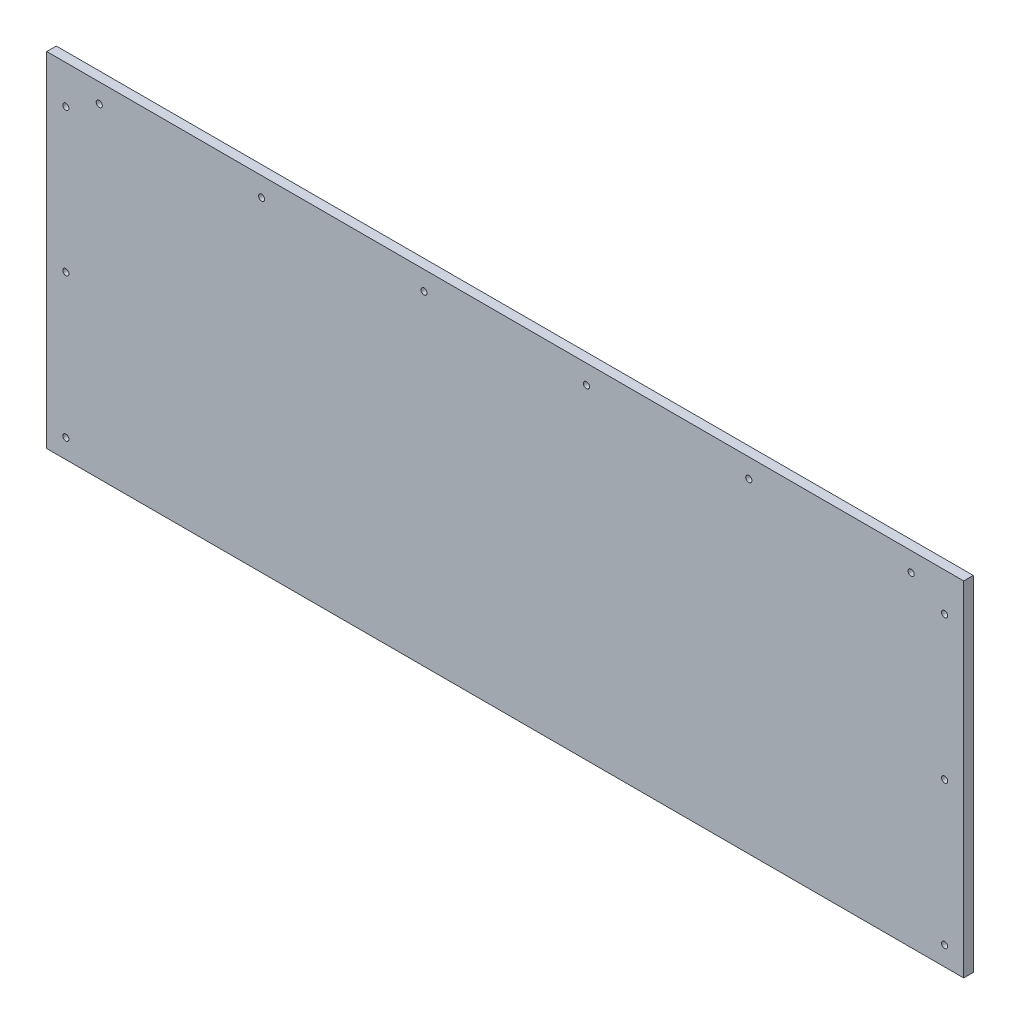
from build123d import *

# Parameters (mm, degrees)
SKETCH1_W           = 609.6
SKETCH1_H           = 228.6
BOSS_EXTRUDE1_DEPTH = 6.35
SKETCH2_R           = 2.032
CUT_EXTRUDE4_DEPTH  = 7.35
SKETCH4_R           = 2.032
CUT_EXTRUDE7_DEPTH  = 7.35


with BuildPart() as part:
    # Sketch1 → Boss-Extrude1 (new body)
    with BuildSketch(Plane.XY):
        with Locations((304.8, 114.3)):
            Rectangle(SKETCH1_W, SKETCH1_H)
    extrude(amount=BOSS_EXTRUDE1_DEPTH)

    # Sketch2 → Cut-Extrude4 (cut, through all)
    with BuildSketch(Plane.XY.offset(6.35)):
        with Locations((12.7, 203.2)):
            Circle(SKETCH2_R)
        with Locations((12.7, 107.95)):
            Circle(SKETCH2_R)
        with Locations((12.7, 12.7)):
            Circle(SKETCH2_R)
        with Locations((596.9, 12.7)):
            Circle(SKETCH2_R)
        with Locations((596.9, 107.95)):
            Circle(SKETCH2_R)
        with Locations((596.9, 203.2)):
            Circle(SKETCH2_R)
    extrude(amount=-CUT_EXTRUDE4_DEPTH, mode=Mode.SUBTRACT)

    # Sketch4 → Cut-Extrude7 (cut, through all)
    with BuildSketch(Plane.XY.offset(6.35)):
        with Locations((34.925, 215.9)):
            Circle(SKETCH4_R)
        with Locations((142.875, 215.9)):
            Circle(SKETCH4_R)
        with Locations((250.825, 215.9)):
            Circle(SKETCH4_R)
        with Locations((358.775, 215.9)):
            Circle(SKETCH4_R)
        with Locations((466.725, 215.9)):
            Circle(SKETCH4_R)
        with Locations((574.675, 215.9)):
            Circle(SKETCH4_R)
    extrude(amount=-CUT_EXTRUDE7_DEPTH, mode=Mode.SUBTRACT)


solid = part.part
